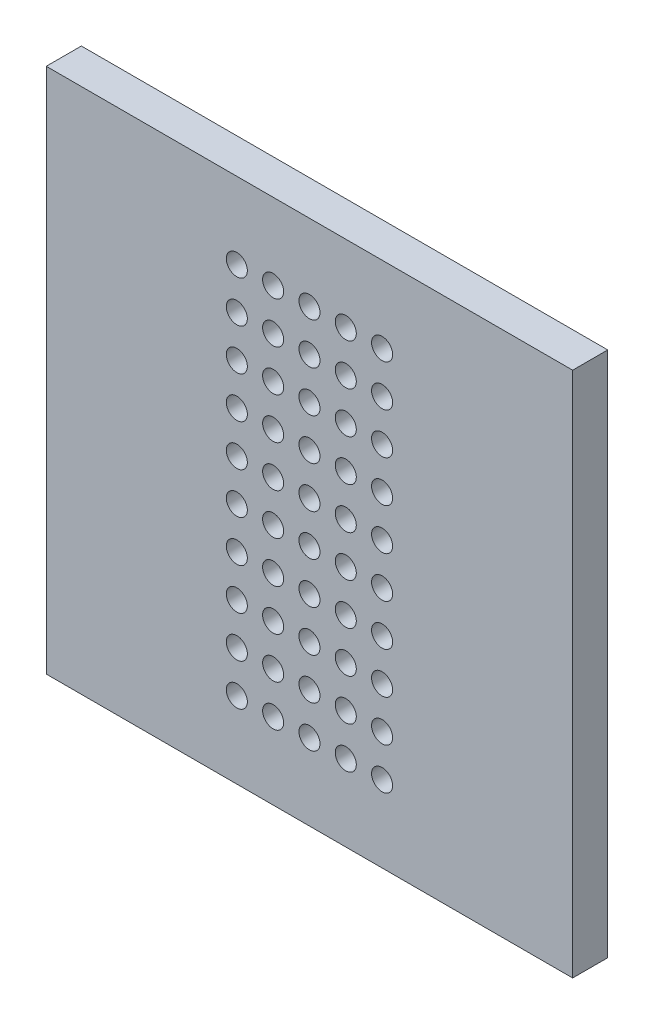
from build123d import *

# Parameters (mm, degrees)
ESQUISSE1_W            = 30
ESQUISSE1_H            = 30
BASE_PLATE_DEPTH       = 2
SKETCH_PERFORATIONS_R  = 0.6
CUT_PERFORATIONS_DEPTH = 10


with BuildPart() as part:
    # Esquisse1 → Base_Plate (new body)
    with BuildSketch(Plane.XY):
        Rectangle(ESQUISSE1_W, ESQUISSE1_H)
    extrude(amount=BASE_PLATE_DEPTH)

    # Sketch_Perforations → Cut_Perforations (cut)
    with BuildSketch(Plane.XY.offset(2)):
        with Locations((-4.14, -10.64)):
            Circle(SKETCH_PERFORATIONS_R)
        with Locations((-4.14, -8.27)):
            Circle(SKETCH_PERFORATIONS_R)
        with Locations((-4.14, -5.91)):
            Circle(SKETCH_PERFORATIONS_R)
        with Locations((-4.14, -3.55)):
            Circle(SKETCH_PERFORATIONS_R)
        with Locations((-4.14, -1.18)):
            Circle(SKETCH_PERFORATIONS_R)
        with Locations((-4.14, 1.18)):
            Circle(SKETCH_PERFORATIONS_R)
        with Locations((-4.14, 3.55)):
            Circle(SKETCH_PERFORATIONS_R)
        with Locations((-4.14, 5.91)):
            Circle(SKETCH_PERFORATIONS_R)
        with Locations((-4.14, 8.27)):
            Circle(SKETCH_PERFORATIONS_R)
        with Locations((-4.14, 10.64)):
            Circle(SKETCH_PERFORATIONS_R)
        with Locations((-2.07, -10.64)):
            Circle(SKETCH_PERFORATIONS_R)
        with Locations((-2.07, -8.27)):
            Circle(SKETCH_PERFORATIONS_R)
        with Locations((-2.07, -5.91)):
            Circle(SKETCH_PERFORATIONS_R)
        with Locations((-2.07, -3.55)):
            Circle(SKETCH_PERFORATIONS_R)
        with Locations((-2.07, -1.18)):
            Circle(SKETCH_PERFORATIONS_R)
        with Locations((-2.07, 1.18)):
            Circle(SKETCH_PERFORATIONS_R)
        with Locations((-2.07, 3.55)):
            Circle(SKETCH_PERFORATIONS_R)
        with Locations((-2.07, 5.91)):
            Circle(SKETCH_PERFORATIONS_R)
        with Locations((-2.07, 8.27)):
            Circle(SKETCH_PERFORATIONS_R)
        with Locations((-2.07, 10.64)):
            Circle(SKETCH_PERFORATIONS_R)
        with Locations((0, -10.64)):
            Circle(SKETCH_PERFORATIONS_R)
        with Locations((0, -8.27)):
            Circle(SKETCH_PERFORATIONS_R)
        with Locations((0, -5.91)):
            Circle(SKETCH_PERFORATIONS_R)
        with Locations((0, -3.55)):
            Circle(SKETCH_PERFORATIONS_R)
        with Locations((0, -1.18)):
            Circle(SKETCH_PERFORATIONS_R)
        with Locations((0, 1.18)):
            Circle(SKETCH_PERFORATIONS_R)
        with Locations((0, 3.55)):
            Circle(SKETCH_PERFORATIONS_R)
        with Locations((0, 5.91)):
            Circle(SKETCH_PERFORATIONS_R)
        with Locations((0, 8.27)):
            Circle(SKETCH_PERFORATIONS_R)
        with Locations((0, 10.64)):
            Circle(SKETCH_PERFORATIONS_R)
        with Locations((2.07, -10.64)):
            Circle(SKETCH_PERFORATIONS_R)
        with Locations((2.07, -8.27)):
            Circle(SKETCH_PERFORATIONS_R)
        with Locations((2.07, -5.91)):
            Circle(SKETCH_PERFORATIONS_R)
        with Locations((2.07, -3.55)):
            Circle(SKETCH_PERFORATIONS_R)
        with Locations((2.07, -1.18)):
            Circle(SKETCH_PERFORATIONS_R)
        with Locations((2.07, 1.18)):
            Circle(SKETCH_PERFORATIONS_R)
        with Locations((2.07, 3.55)):
            Circle(SKETCH_PERFORATIONS_R)
        with Locations((2.07, 5.91)):
            Circle(SKETCH_PERFORATIONS_R)
        with Locations((2.07, 8.27)):
            Circle(SKETCH_PERFORATIONS_R)
        with Locations((2.07, 10.64)):
            Circle(SKETCH_PERFORATIONS_R)
        with Locations((4.14, -10.64)):
            Circle(SKETCH_PERFORATIONS_R)
        with Locations((4.14, -8.27)):
            Circle(SKETCH_PERFORATIONS_R)
        with Locations((4.14, -5.91)):
            Circle(SKETCH_PERFORATIONS_R)
        with Locations((4.14, -3.55)):
            Circle(SKETCH_PERFORATIONS_R)
        with Locations((4.14, -1.18)):
            Circle(SKETCH_PERFORATIONS_R)
        with Locations((4.14, 1.18)):
            Circle(SKETCH_PERFORATIONS_R)
        with Locations((4.14, 3.55)):
            Circle(SKETCH_PERFORATIONS_R)
        with Locations((4.14, 5.91)):
            Circle(SKETCH_PERFORATIONS_R)
        with Locations((4.14, 8.27)):
            Circle(SKETCH_PERFORATIONS_R)
        with Locations((4.14, 10.64)):
            Circle(SKETCH_PERFORATIONS_R)
    extrude(amount=-CUT_PERFORATIONS_DEPTH, mode=Mode.SUBTRACT)


solid = part.part
